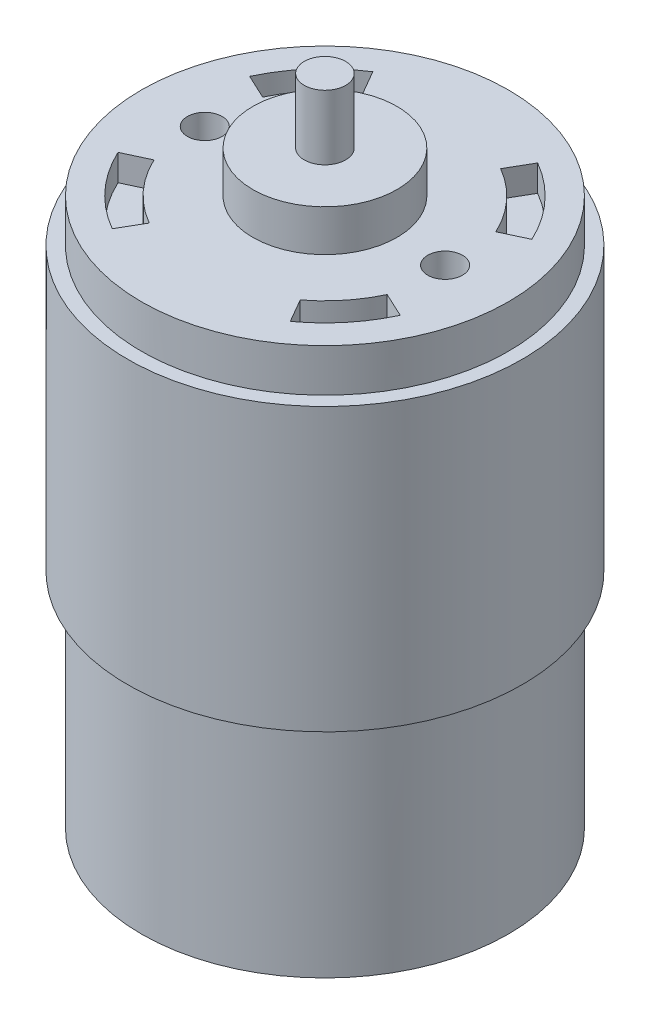
from build123d import *

# Parameters (mm, degrees)
SKETCH2_R            = 22.1488
BOSS_EXTRUDE4_DEPTH  = 66.0908
SKETCH4_R            = 8.6995
BOSS_EXTRUDE5_DEPTH  = 5.0038
SKETCH9_R            = 2.5019
BOSS_EXTRUDE6_DEPTH  = 7.7978
SKETCH10_R           = 8.7503
BOSS_EXTRUDE7_DEPTH  = 6.7056
SKETCH11_R           = 2.5019
BOSS_EXTRUDE8_DEPTH  = 2.413
SKETCH12_R           = 23.8125
BOSS_EXTRUDE9_DEPTH  = 34.0106
SKETCH13_R           = 2.0955
CUT_EXTRUDE1_DEPTH   = 3.175
CUT_EXTRUDE2_DEPTH   = 3.175
SKETCH15_R           = 20.958175
SKETCH15_R_2         = 8.7503
CUT_EXTRUDE3_DEPTH   = 3.175
SKETCH16_R           = 7.1628
SKETCH16_R_2         = 2.5019
CUT_EXTRUDE4_DEPTH   = 2.54
BOSS_EXTRUDE12_DEPTH = 3.175
BOSS_EXTRUDE13_DEPTH = 3.175
SKETCH20_R           = 1.5875
CUT_EXTRUDE5_DEPTH   = 3.175


with BuildPart() as part:
    # Sketch2 → Boss-Extrude4 (new body)
    with BuildSketch(Plane(origin=(0, 0, 0), x_dir=(1, 0, 0), z_dir=(0, 1, 0))):
        Circle(SKETCH2_R)
    extrude(amount=BOSS_EXTRUDE4_DEPTH)

    # Sketch4 → Boss-Extrude5 (add)
    with BuildSketch(Plane(origin=(0, 66.0908, 0), x_dir=(1, 0, 0), z_dir=(0, 1, 0))):
        Circle(SKETCH4_R)
    extrude(amount=BOSS_EXTRUDE5_DEPTH)

    # Sketch9 → Boss-Extrude6 (add)
    with BuildSketch(Plane(origin=(0, 71.0946, 0), x_dir=(1, 0, 0), z_dir=(0, 1, 0))):
        Circle(SKETCH9_R)
    extrude(amount=BOSS_EXTRUDE6_DEPTH)

    # Sketch10 → Boss-Extrude7 (add)
    with BuildSketch(Plane.XZ):
        Circle(SKETCH10_R)
    extrude(amount=BOSS_EXTRUDE7_DEPTH)

    # Sketch11 → Boss-Extrude8 (add)
    with BuildSketch(Plane.XZ.offset(6.7056)):
        Circle(SKETCH11_R)
    extrude(amount=BOSS_EXTRUDE8_DEPTH)

    # Sketch12 → Boss-Extrude9 (add)
    with BuildSketch(Plane(origin=(0, 60.9092, 0), x_dir=(-1, 0, 0), z_dir=(0, -1, 0))):
        Circle(SKETCH12_R)
    extrude(amount=BOSS_EXTRUDE9_DEPTH)

    # Sketch13 → Cut-Extrude1 (cut)
    with BuildSketch(Plane(origin=(0, 66.0908, 0), x_dir=(1, 0, 0), z_dir=(0, 1, 0))):
        with Locations((-14.5034, 0)):
            Circle(SKETCH13_R)
        with Locations((14.5034, 0)):
            Circle(SKETCH13_R)
    extrude(amount=-CUT_EXTRUDE1_DEPTH, mode=Mode.SUBTRACT)

    # Sketch14 → Cut-Extrude2 (cut)
    with BuildSketch(Plane(origin=(0, 66.0908, 0), x_dir=(1, 0, 0), z_dir=(0, 1, 0))):
        with BuildLine():
            Line((-14.070005184, -6.560951168), (-17.033311719, -7.942763698))
            ThreePointArc((-17.033311719, -7.942763698), (-13.856523006, -12.697163994), (-9.397090019, -16.276237356))
            Line((-9.397090019, -16.276237356), (-7.76226652, -13.444639995))
            ThreePointArc((-7.76226652, -13.444639995), (-11.445886375, -10.4882225), (-14.070005184, -6.560951168))
        make_face()
        with BuildLine():
            ThreePointArc((-10.080336815, 15.862156631), (-14.123267338, 12.399779151), (-17.033311719, 7.942763698))
            Line((-17.033311719, 7.942763698), (-14.070005184, 6.560951168))
            ThreePointArc((-14.070005184, 6.560951168), (-11.711998853, 10.190201616), (-8.44372295, 13.027458265))
            Line((-8.44372295, 13.027458265), (-10.080336815, 15.862156631))
        make_face()
        with BuildLine():
            ThreePointArc((17.033311719, 7.942763698), (13.856523006, 12.697163994), (9.397090019, 16.276237356))
            Line((9.397090019, 16.276237356), (7.76226652, 13.444639995))
            ThreePointArc((7.76226652, 13.444639995), (11.445886375, 10.4882225), (14.070005184, 6.560951168))
            Line((14.070005184, 6.560951168), (17.033311719, 7.942763698))
        make_face()
        with BuildLine():
            Line((9.385927189, -12.365900571), (11.031460095, -15.21604717))
            ThreePointArc((11.031460095, -15.21604717), (14.495965555, -11.961947414), (17.033311719, -7.942763698))
            Line((17.033311719, -7.942763698), (14.070005184, -6.560951168))
            ThreePointArc((14.070005184, -6.560951168), (12.081785889, -9.748926908), (9.385927189, -12.365900571))
        make_face()
    extrude(amount=-CUT_EXTRUDE2_DEPTH, mode=Mode.SUBTRACT)

    # Sketch15 → Cut-Extrude3 (cut)
    with BuildSketch(Plane.XZ):
        Circle(SKETCH15_R)
        Circle(SKETCH15_R_2, mode=Mode.SUBTRACT)
    extrude(amount=-CUT_EXTRUDE3_DEPTH, mode=Mode.SUBTRACT)

    # Sketch16 → Cut-Extrude4 (cut)
    with BuildSketch(Plane.XZ.offset(6.7056)):
        Circle(SKETCH16_R)
        Circle(SKETCH16_R_2, mode=Mode.SUBTRACT)
    extrude(amount=-CUT_EXTRUDE4_DEPTH, mode=Mode.SUBTRACT)

    # Sketch18 → Boss-Extrude12 (add)
    with BuildSketch(Plane.XZ):
        with BuildLine():
            ThreePointArc((20.865163654, 0), (20.780212376, 1.88091146), (20.52605029, 3.746506881))
            Line((20.52605029, 3.746506881), (17.399, 3.746506881))
            Line((17.399, 3.746506881), (17.399, -2.603493119))
            Line((17.399, -2.603493119), (20.702098393, -2.603493119))
            ThreePointArc((20.702098393, -2.603493119), (20.824357436, -1.304297387), (20.865163654, 0))
        make_face()
    extrude(amount=-BOSS_EXTRUDE12_DEPTH)

    # Sketch19 → Boss-Extrude13 (add)
    with BuildSketch(Plane(origin=(0, 0, 0), x_dir=(-1, 0, 0), z_dir=(0, -1, 0))):
        with BuildLine():
            Line((20.716285244, -3.175), (17.399, -3.175))
            Line((17.399, -3.175), (17.399, 3.175))
            Line((17.399, 3.175), (20.716285244, 3.175))
            ThreePointArc((20.716285244, 3.175), (20.958175, 0), (20.716285244, -3.175))
        make_face()
    extrude(amount=-BOSS_EXTRUDE13_DEPTH)

    # Sketch20 → Cut-Extrude5 (cut)
    with BuildSketch(Plane(origin=(0, 3.175, 0), x_dir=(-1, 0, 0), z_dir=(0, -1, 0))):
        with Locations((-15.1765, 6.730993119)):
            Circle(SKETCH20_R)
    extrude(amount=-CUT_EXTRUDE5_DEPTH, mode=Mode.SUBTRACT)


solid = part.part
